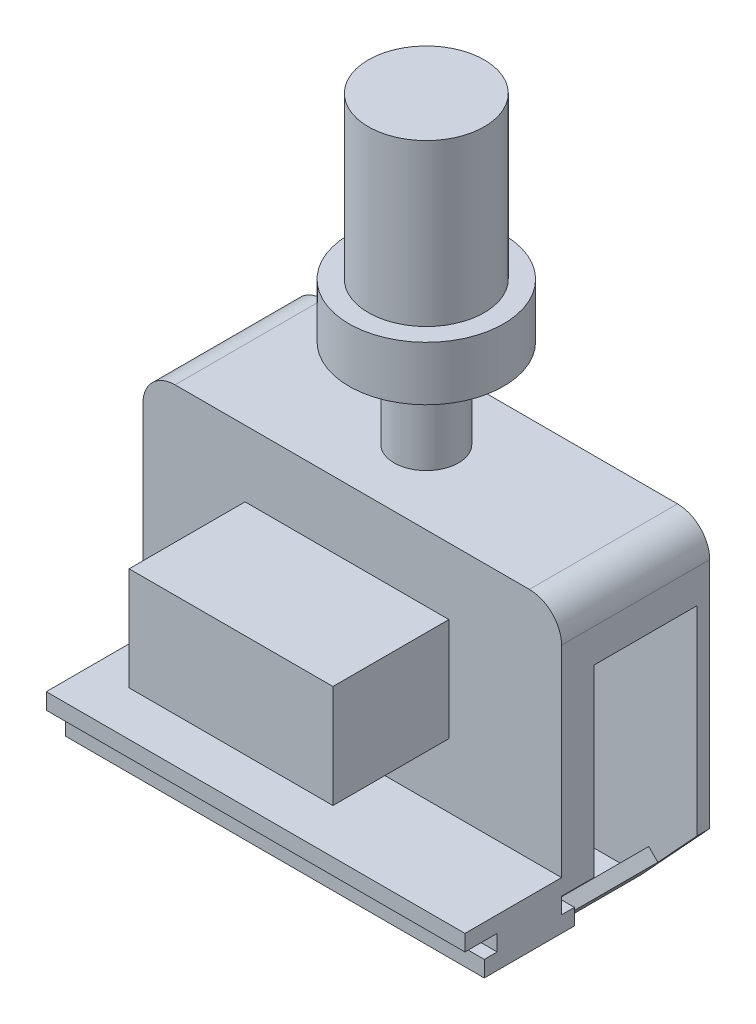
from build123d import *

# Parameters (mm, degrees)
BOSS_EXTRUDE1_DEPTH = 5
SKETCH1_3_W         = 65
SKETCH1_3_H         = 2.5
BOSS_EXTRUDE2_DEPTH = 20
SKETCH2_W           = 65
SKETCH2_H           = 2.5
BOSS_EXTRUDE3_DEPTH = 5
SKETCH2_3_W         = 65
SKETCH2_3_H         = 2.5
BOSS_EXTRUDE4_DEPTH = 7
SKETCH1_5_W         = 31.646470679
SKETCH1_5_H         = 16.00939105
BOSS_EXTRUDE5_DEPTH = 23
BOSS_EXTRUDE6_START = 16
BOSS_EXTRUDE6_DEPTH = 16
BOSS_EXTRUDE7_DEPTH = 2


with BuildPart() as part:
    # Sketch1 → Boss-Extrude1 (new body)
    with BuildSketch(Plane.XY):
        with BuildLine():
            Line((0, 38.75), (0, 7.5))
            Line((0, 7.5), (65, 7.5))
            Line((65, 7.5), (65, 38.75))
            ThreePointArc((65, 38.75), (63.535533906, 42.285533906), (60, 43.75))
            Line((60, 43.75), (5, 43.75))
            ThreePointArc((5, 43.75), (1.464466094, 42.285533906), (0, 38.75))
        make_face()
    extrude(amount=BOSS_EXTRUDE1_DEPTH)

    # Sketch1_3 → Boss-Extrude2 (add)
    with BuildSketch(Plane.XY):
        with Locations((32.5, 6.25)):
            Rectangle(SKETCH1_3_W, SKETCH1_3_H)
    extrude(amount=BOSS_EXTRUDE2_DEPTH)

    # Sketch2 → Boss-Extrude3 (add, symmetric)
    with BuildSketch(Plane.XY.offset(10)):
        with Locations((32.5, 3.75)):
            Rectangle(SKETCH2_W, SKETCH2_H)
    extrude(amount=BOSS_EXTRUDE3_DEPTH, both=True)

    # Sketch2_3 → Boss-Extrude4 (add, symmetric)
    with BuildSketch(Plane.XY.offset(10)):
        with Locations((32.5, 1.25)):
            Rectangle(SKETCH2_3_W, SKETCH2_3_H)
    extrude(amount=BOSS_EXTRUDE4_DEPTH, both=True)

    # Sketch1_5 → Boss-Extrude5 (add)
    with BuildSketch(Plane.XY):
        with Locations((31.682365604, 25.44274044)):
            Rectangle(SKETCH1_5_W, SKETCH1_5_H)
    extrude(amount=BOSS_EXTRUDE5_DEPTH)

    # Sketch3 → Boss-Extrude6 (add)
    with BuildSketch(Plane(origin=(0, 0, 0), x_dir=(-1, 0, 0), z_dir=(0, 0, -1)).offset(BOSS_EXTRUDE6_START)):
        with BuildLine():
            Line((-2, 33.67400262), (0, 33.67400262))
            Line((0, 33.67400262), (0, 38.75))
            ThreePointArc((0, 38.75), (-1.464466094, 42.285533906), (-5, 43.75))
            Line((-5, 43.75), (-60, 43.75))
            ThreePointArc((-60, 43.75), (-63.535533906, 42.285533906), (-65, 38.75))
            Line((-65, 38.75), (-65, 33.551986264))
            Line((-65, 33.551986264), (-63, 33.551986264))
            Line((-63, 33.551986264), (-63, 38.75))
            ThreePointArc((-63, 38.75), (-62.121320344, 40.871320344), (-60, 41.75))
            Line((-60, 41.75), (-5, 41.75))
            ThreePointArc((-5, 41.75), (-2.878679656, 40.871320344), (-2, 38.75))
            Line((-2, 38.75), (-2, 33.67400262))
        make_face()
        Polygon((-9.704230369, -9.009552441), (-4.852115184, -4.157437257), (-6.266328747, -2.743223694), (-10.532657494, -7.009552441), (-53.41460101, -7.009552441), (-57.531707428, -2.550119806), (-58.947047068, -3.965459446), (-54.290161463, -9.009552441), align=None)
    extrude(amount=-BOSS_EXTRUDE6_DEPTH)


with BuildPart() as boss_extrude6_piece_1:
    # of the separate pieces the step leaves, piece 1, a body of its own (boss_extrude6_pieces)
    add(part.part.solids().sort_by_distance((65, 2.5, 5))[0])



with BuildPart() as boss_extrude6_piece_2:
    # of the separate pieces the step leaves, piece 2, a body of its own (boss_extrude6_pieces)
    add(part.part.solids().sort_by_distance((58.947047068, -3.965459446, -16))[0])


with BuildPart() as boss_extrude6_piece_1_1:
    add(boss_extrude6_piece_1.part)

    add(boss_extrude6_piece_2.part)  # Boss-Extrude7 merges Boss-Extrude6 piece 2
    # Sketch4 → Boss-Extrude7 (add)
    with BuildSketch(Plane(origin=(0, 0, -16), x_dir=(-1, 0, 0), z_dir=(0, 0, -1))):
        with BuildLine():
            Line((-54.290161463, -9.009552441), (-9.704230369, -9.009552441))
            Line((-9.704230369, -9.009552441), (0, 0.694677928))
            Line((0, 0.694677928), (0, 38.75))
            ThreePointArc((0, 38.75), (-1.464466094, 42.285533906), (-5, 43.75))
            Line((-5, 43.75), (-60, 43.75))
            ThreePointArc((-60, 43.75), (-63.535533906, 42.285533906), (-65, 38.75))
            Line((-65, 38.75), (-65, 2.590780084))
            Line((-65, 2.590780084), (-54.290161463, -9.009552441))
        make_face()
    extrude(amount=BOSS_EXTRUDE7_DEPTH)

    # Sketch5 → Revolve1 (revolve)
    with BuildSketch(Plane.XY.offset(-6.5)):
        Polygon((32.5, 90.95), (23.5, 90.95), (23.5, 65.95), (20.5, 65.95), (20.5, 57.55), (27.5, 57.55), (27.5, 43.75), (32.5, 43.75), align=None)
    revolve(axis=Axis((32.5, 92.408225654, -6.5), (0, -1, 0)))


solid = boss_extrude6_piece_1_1.part
